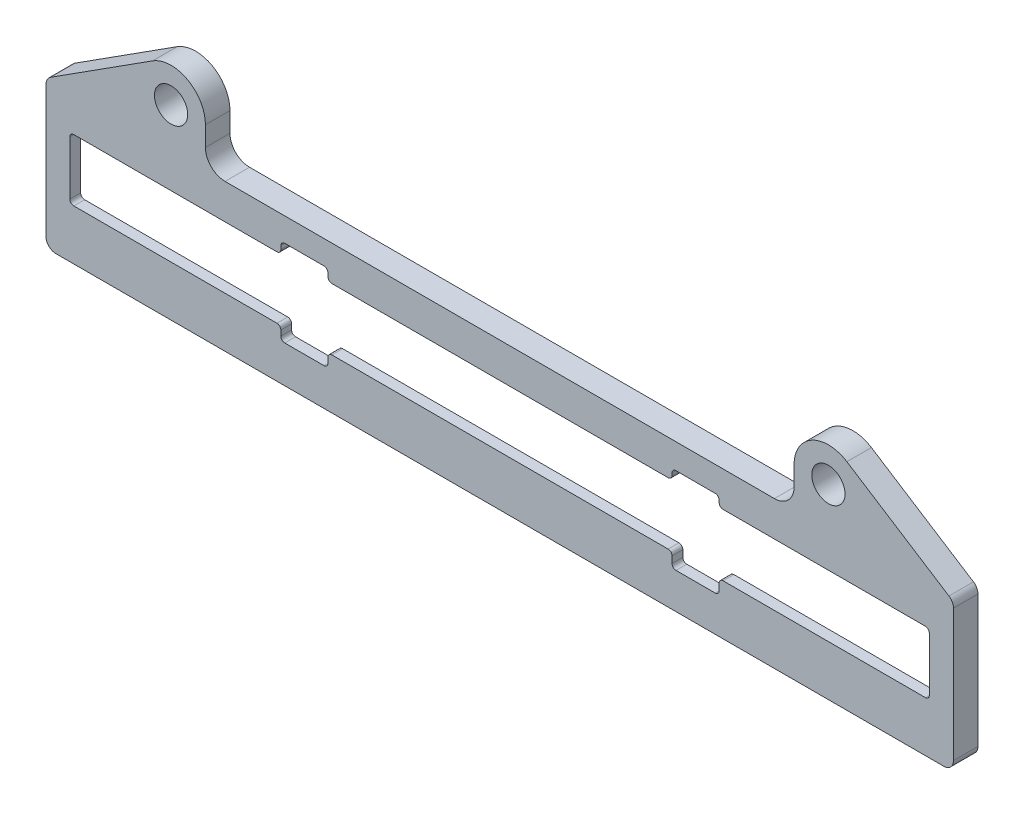
from build123d import *

# Parameters (mm, degrees)
BOSS_EXTRUDE1_DEPTH   = 3.175
F_6_CLEARANCE_HOLE1_D = 4.3053
FILLET3_R             = 1.27
CUT_EXTRUDE3_DEPTH    = 1.778
SKETCH9_W             = 6.096
SKETCH9_H             = 11.176
CUT_EXTRUDE4_DEPTH    = 4.175
SKETCH10_W            = 111.2535
SKETCH10_H            = 8
CUT_EXTRUDE5_DEPTH    = 2.397
FILLET5_R             = 0.508


with BuildPart() as part:
    # Sketch1 → Boss-Extrude1 (new body)
    with BuildSketch(Plane.XY):
        with BuildLine():
            Line((58.7375, -67.1354797), (58.7375, -48.0854797))
            Line((58.7375, -48.0854797), (44.939976119, -39.26086832))
            ThreePointArc((44.939976119, -39.26086832), (40.410479427, -39.106525106), (38.1, -43.0054797))
            Line((38.1, -43.0054797), (38.1, -45.5454797))
            ThreePointArc((38.1, -45.5454797), (37.356051224, -47.341530924), (35.56, -48.0854797))
            Line((35.56, -48.0854797), (-35.56, -48.0854797))
            ThreePointArc((-35.56, -48.0854797), (-37.356051224, -47.341530924), (-38.1, -45.5454797))
            Line((-38.1, -45.5454797), (-38.1, -43.0054797))
            ThreePointArc((-38.1, -43.0054797), (-40.410479427, -39.106525106), (-44.939976119, -39.26086832))
            Line((-44.939976119, -39.26086832), (-58.7375, -48.0854797))
            Line((-58.7375, -48.0854797), (-58.7375, -67.1354797))
            Line((-58.7375, -67.1354797), (58.7375, -67.1354797))
        make_face()
    extrude(amount=BOSS_EXTRUDE1_DEPTH)

    # #6 Clearance Hole1 (through all)
    with Locations(Plane(origin=(0, 0, 0), x_dir=(-1, 0, 0), z_dir=(0, 0, -1))):
        with Locations((42.545, -43.0054797), (-42.545, -43.0054797)):
            Hole(F_6_CLEARANCE_HOLE1_D / 2)

    # Fillet3
    fillet3_edges = [part.edges().sort_by_distance(p)[0] for p in [
        (-58.7375, -67.1354797, 1.5875),
        (-58.7375, -48.0854797, 1.5875),
        (58.7375, -48.0854797, 1.5875),
        (58.7375, -67.1354797, 1.5875),
    ]]
    fillet(fillet3_edges, radius=FILLET3_R)

    # Sketch8 → Cut-Extrude3 (cut)
    with BuildSketch(Plane(origin=(0, 0, 0), x_dir=(-1, 0, 0), z_dir=(0, 0, -1))):
        with BuildLine():
            Line((58.028, -61.8742797), (58.028, -51.3742797))
            ThreePointArc((58.028, -51.3742797), (57.293423807, -49.600855893), (55.52, -48.8662797))
            Line((55.52, -48.8662797), (-55.48, -48.8662797))
            ThreePointArc((-55.48, -48.8662797), (-57.253423807, -49.600855893), (-57.988, -51.3742797))
            Line((-57.988, -51.3742797), (-57.988, -61.8742797))
            ThreePointArc((-57.988, -61.8742797), (-57.253423807, -63.647703507), (-55.48, -64.3822797))
            Line((-55.48, -64.3822797), (55.52, -64.3822797))
            ThreePointArc((55.52, -64.3822797), (57.293423807, -63.647703507), (58.028, -61.8742797))
        make_face()
    extrude(amount=-CUT_EXTRUDE3_DEPTH, mode=Mode.SUBTRACT)

    # Sketch9 → Cut-Extrude4 (cut, through all)
    with BuildSketch(Plane.XY.offset(3.175)):
        with Locations((-25.29, -56.7473797)):
            Rectangle(SKETCH9_W, SKETCH9_H)
        with Locations((25.355, -56.9192547)):
            Rectangle(SKETCH9_W, SKETCH9_H)
    extrude(amount=-CUT_EXTRUDE4_DEPTH, mode=Mode.SUBTRACT)

    # Sketch10 → Cut-Extrude5 (cut, through all)
    with BuildSketch(Plane(origin=(0, 0, 1.778), x_dir=(-1, 0, 0), z_dir=(0, 0, -1))):
        with Locations((0.02, -56.6242797)):
            Rectangle(SKETCH10_W, SKETCH10_H)
    extrude(amount=-CUT_EXTRUDE5_DEPTH, mode=Mode.SUBTRACT)

    # Fillet5
    fillet5_edges = [part.edges().sort_by_distance(p)[0] for p in [
        (-22.242, -51.1593797, 2.4765),
        (-22.242, -62.3353797, 2.4765),
        (-28.338, -62.3353797, 2.4765),
        (-28.338, -51.1593797, 2.4765),
        (28.403, -51.3312547, 2.4765),
        (28.403, -62.5072547, 2.4765),
        (22.307, -62.5072547, 2.4765),
        (22.307, -51.3312547, 2.4765),
        (-28.338, -60.6242797, 2.4765),
        (-28.338, -52.6242797, 2.4765),
        (28.403, -52.6242797, 2.4765),
        (55.60675, -52.6242797, 2.4765),
        (22.307, -52.6242797, 2.4765),
        (-22.242, -52.6242797, 2.4765),
        (28.403, -60.6242797, 2.4765),
        (22.307, -60.6242797, 2.4765),
        (-22.242, -60.6242797, 2.4765),
        (-55.64675, -60.6242797, 2.4765),
        (55.60675, -60.6242797, 2.4765),
        (-55.64675, -52.6242797, 2.4765),
    ]]
    fillet(fillet5_edges, radius=FILLET5_R)


solid = part.part
